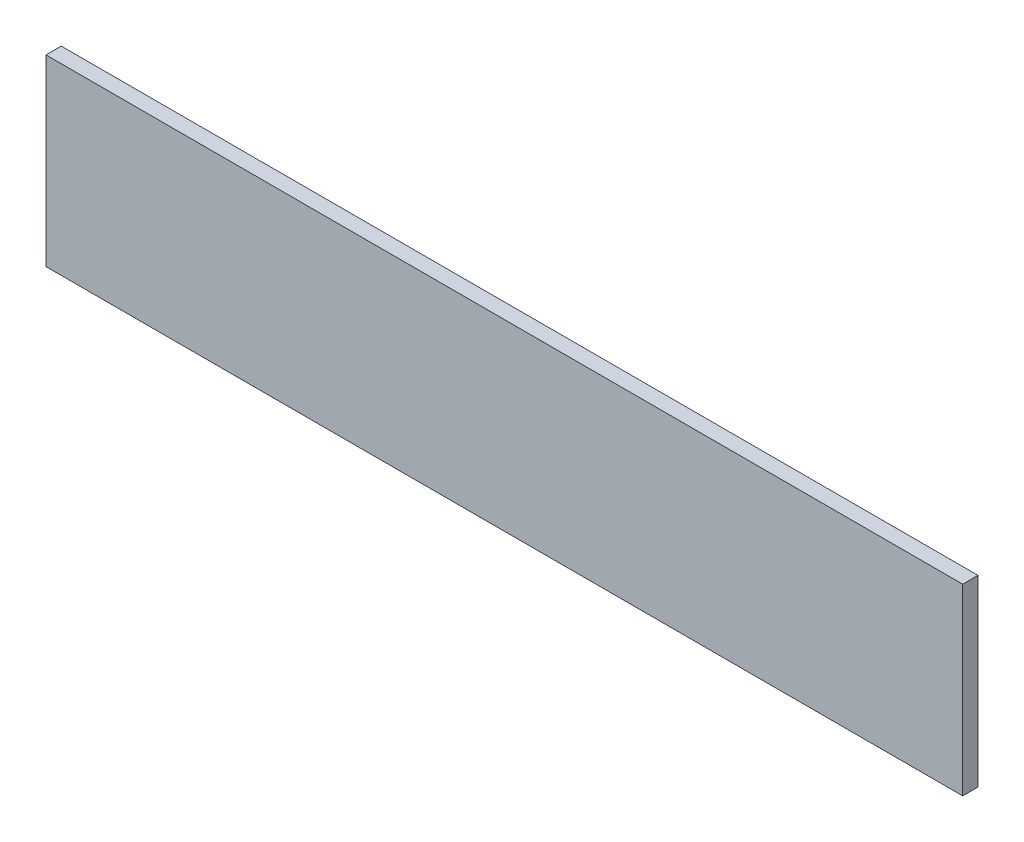
from build123d import *

# Parameters (mm, degrees)
SKETCH1_W           = 6.35
SKETCH1_H           = 76.2
BOSS_EXTRUDE1_DEPTH = 381


with BuildPart() as part:
    # Sketch1 → Boss-Extrude1 (new body)
    with BuildSketch(Plane(origin=(0, 0, 0), x_dir=(0, 0, -1), z_dir=(1, 0, 0))):
        Rectangle(SKETCH1_W, SKETCH1_H)
    extrude(amount=BOSS_EXTRUDE1_DEPTH)


solid = part.part
